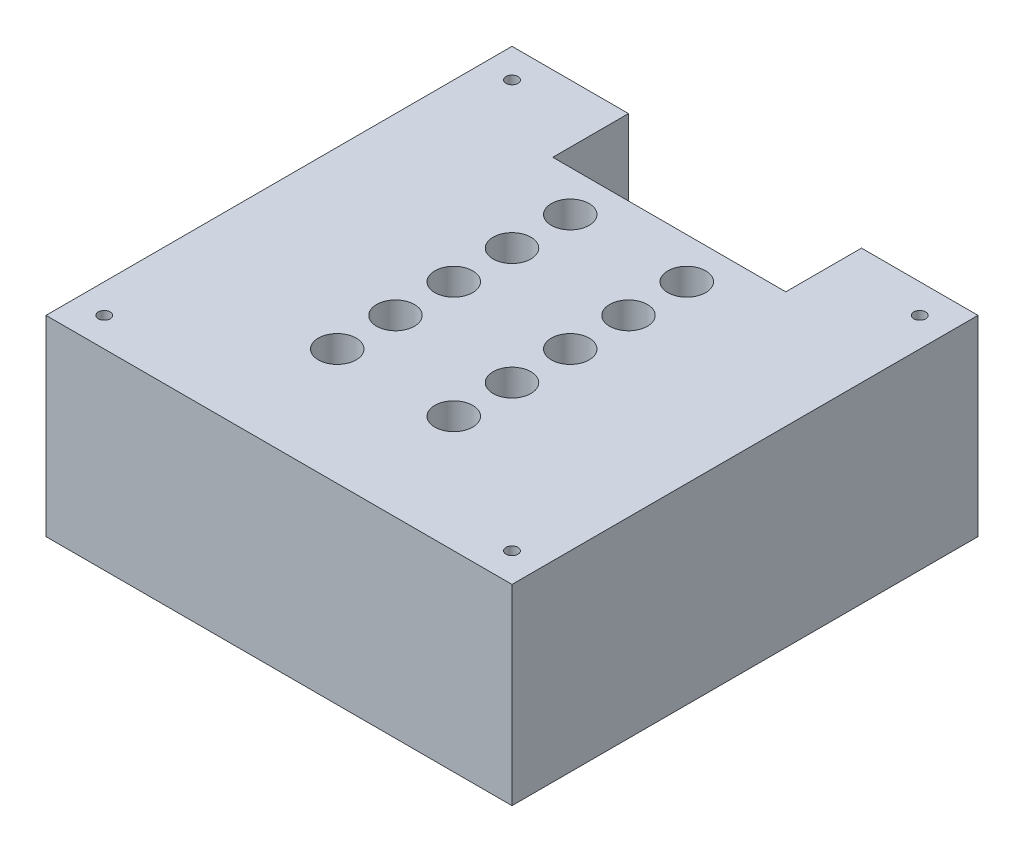
from build123d import *

# Parameters (mm, degrees)
SKETCH1_W                      = 80
SKETCH1_H                      = 80
BOSS_EXTRUDE1_DEPTH            = 32.9
M2_5X0_45_TAPPED_HOLE1_D       = 2.05
M2_5X0_45_TAPPED_HOLE1_DEPTH   = 6.35
M2_5X0_45_TAPPED_HOLE1_TIP     = 0.615882135
CBORE_FOR_M3_SHCS1_D           = 3.2
CBORE_FOR_M3_SHCS1_CBORE_D     = 6.5
CBORE_FOR_M3_SHCS1_CBORE_DEPTH = 28
SKETCH25_W                     = 40
SKETCH25_H                     = 32.9
CUT_EXTRUDE2_DEPTH             = 13


with BuildPart() as part:
    # Sketch1 → Boss-Extrude1 (new body)
    with BuildSketch(Plane(origin=(0, 0, 0), x_dir=(1, 0, 0), z_dir=(0, 1, 0))):
        with Locations((5.874226931, -9.806779272)):
            Rectangle(SKETCH1_W, SKETCH1_H)
    extrude(amount=BOSS_EXTRUDE1_DEPTH)

    # M2.5x0.45 Tapped Hole1
    with Locations(Plane(origin=(-29.125773069, 32.9, -25.193220728), x_dir=(0, 0, 1), z_dir=(0, 1, 0))):
        with Locations((0, 0), (0, 70), (70, 70), (70, 0)):
            Hole(M2_5X0_45_TAPPED_HOLE1_D / 2, depth=M2_5X0_45_TAPPED_HOLE1_DEPTH)
            with Locations((0, 0, -(M2_5X0_45_TAPPED_HOLE1_DEPTH + M2_5X0_45_TAPPED_HOLE1_TIP / 2))):  # 118° drill point
                Cone(0, M2_5X0_45_TAPPED_HOLE1_D / 2, M2_5X0_45_TAPPED_HOLE1_TIP, mode=Mode.SUBTRACT)

    # CBORE for M3 SHCS1 (through all)
    with Locations(Plane(origin=(0, 32.9, 0), x_dir=(1, 0, 0), z_dir=(0, 1, 0))):
        with Locations((15.874226931, -29.806779272), (-4.125773069, -29.806779272), (-4.125773069, -19.806779272), (-4.125773069, -9.806779272), (-4.125773069, 0.193220728), (-4.125773069, 10.193220728), (15.874226931, -19.806779272), (15.874226931, -9.806779272), (15.874226931, 0.193220728), (15.874226931, 10.193220728)):
            CounterBoreHole(CBORE_FOR_M3_SHCS1_D / 2, CBORE_FOR_M3_SHCS1_CBORE_D / 2, CBORE_FOR_M3_SHCS1_CBORE_DEPTH)

    # Sketch25 → Cut-Extrude2 (cut)
    with BuildSketch(Plane(origin=(0, 0, -30.193220728), x_dir=(-1, 0, 0), z_dir=(0, 0, -1))):
        with Locations((-5.874226931, 16.45)):
            Rectangle(SKETCH25_W, SKETCH25_H)
    extrude(amount=-CUT_EXTRUDE2_DEPTH, mode=Mode.SUBTRACT)


solid = part.part
